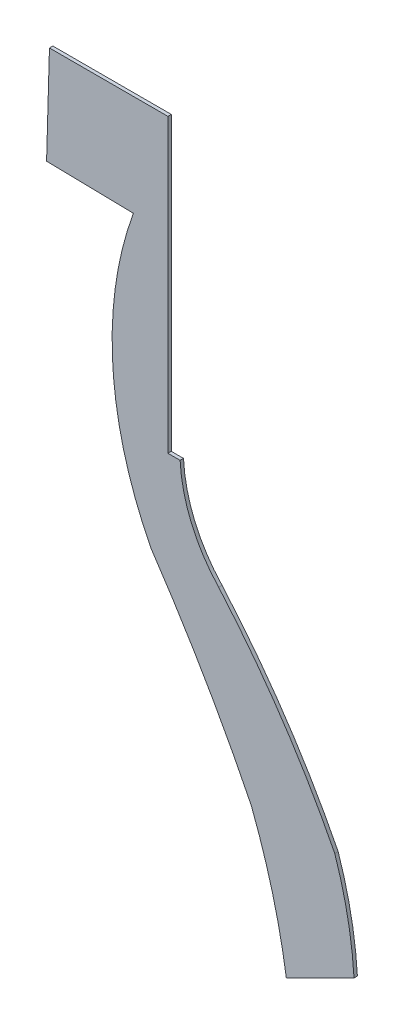
from build123d import *

# Parameters (mm, degrees)
SALIENTE_EXTRUIR1_DEPTH = 0.1


with BuildPart() as part:
    # Model → Saliente-Extruir1 (new body)
    with BuildSketch(Plane.XY):
        with BuildLine():
            Line((12.698297287, 13.802618595), (15.263616387, 13.750921574))
            ThreePointArc((15.263616387, 13.750921574), (14.654945019, 9.542094065), (15.782845256, 5.441782991))
            ThreePointArc((15.782845256, 5.441782991), (17.35183527, 2.94274106), (18.745376573, 0.341782991))
            ThreePointArc((18.745376573, 0.341782991), (19.372340085, -1.579426143), (19.782845256, -3.558217009))
            Line((19.782845256, -3.558217009), (21.782845256, -2.558217009))
            ThreePointArc((21.782845256, -2.558217009), (21.595097776, -1.089252971), (21.213993411, 0.341782991))
            ThreePointArc((21.213993411, 0.341782991), (19.656131166, 2.997887435), (17.782845256, 5.441782991))
            ThreePointArc((17.782845256, 5.441782991), (16.97662621, 6.680138732), (16.643698969, 8.119817009))
            Line((16.643698969, 8.119817009), (16.284102713, 8.119817009))
            Line((16.284102713, 8.119817009), (16.284102713, 16.741782991))
            Line((16.284102713, 16.741782991), (12.782845256, 16.741782991))
            Line((12.782845256, 16.741782991), (12.698297287, 13.802618595))
        make_face()
    extrude(amount=SALIENTE_EXTRUIR1_DEPTH)


solid = part.part
